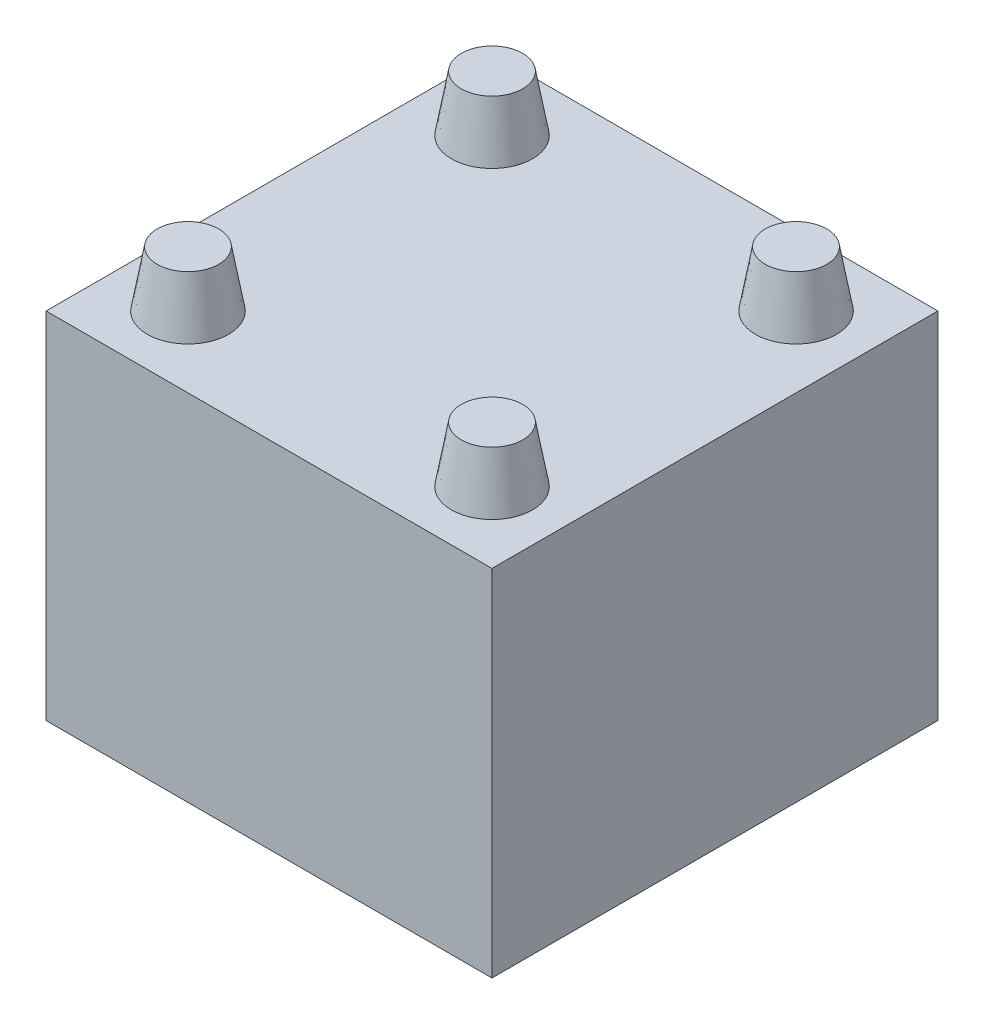
from build123d import *

# Parameters (mm, degrees)
SKETCH1_W           = 22
SKETCH1_H           = 22
BOSS_EXTRUDE1_DEPTH = 3
SKETCH2_R           = 2
BOSS_EXTRUDE2_DEPTH = 14.5
SKETCH3_R           = 2
BOSS_EXTRUDE3_DEPTH = 2.75
BOSS_EXTRUDE3_TAPER = 10
BOSS_EXTRUDE4_DEPTH = 14.5
BOSS_EXTRUDE5_DEPTH = 14.5
SKETCH6_W           = 22
SKETCH6_H           = 22
BOSS_EXTRUDE6_DEPTH = 14.5


with BuildPart() as part:
    # Sketch1 → Boss-Extrude1 (new body)
    with BuildSketch(Plane(origin=(0, 0, 0), x_dir=(1, 0, 0), z_dir=(0, 1, 0))):
        Rectangle(SKETCH1_W, SKETCH1_H)
    extrude(amount=BOSS_EXTRUDE1_DEPTH)

    # Sketch2 → Boss-Extrude2 (add)
    with BuildSketch(Plane(origin=(0, 3, 0), x_dir=(1, 0, 0), z_dir=(0, 1, 0))):
        with Locations((-7.5, 7.5)):
            Circle(SKETCH2_R)
        with Locations((7.5, 7.5)):
            Circle(SKETCH2_R)
        with Locations((7.5, -7.5)):
            Circle(SKETCH2_R)
        with Locations((-7.5, -7.5)):
            Circle(SKETCH2_R)
    extrude(amount=BOSS_EXTRUDE2_DEPTH)

    # Sketch3 → Boss-Extrude3 (add)
    with BuildSketch(Plane(origin=(0, 17.5, 0), x_dir=(1, 0, 0), z_dir=(0, 1, 0))):
        with Locations((7.5, -7.5)):
            Circle(SKETCH3_R)
        with Locations((7.5, 7.5)):
            Circle(SKETCH3_R)
        with Locations((-7.5, 7.5)):
            Circle(SKETCH3_R)
        with Locations((-7.5, -7.5)):
            Circle(SKETCH3_R)
    extrude(amount=BOSS_EXTRUDE3_DEPTH, taper=BOSS_EXTRUDE3_TAPER)

    # Sketch4 → Boss-Extrude4 (add)
    with BuildSketch(Plane(origin=(0, 3, 0), x_dir=(1, 0, 0), z_dir=(0, 1, 0))):
        Polygon((-7.217157288, -7.782842712), (7.782842712, 7.217157288), (7.217157288, 7.782842712), (-7.782842712, -7.217157288), align=None)
    extrude(amount=BOSS_EXTRUDE4_DEPTH)

    # Sketch5 → Boss-Extrude5 (add)
    with BuildSketch(Plane(origin=(0, 3, 0), x_dir=(1, 0, 0), z_dir=(0, 1, 0))):
        Polygon((-7.217157288, 7.782842712), (7.782842712, -7.217157288), (7.217157288, -7.782842712), (-7.782842712, 7.217157288), align=None)
    extrude(amount=BOSS_EXTRUDE5_DEPTH)

    # Sketch6 → Boss-Extrude6 (add)
    with BuildSketch(Plane(origin=(0, 3, 0), x_dir=(1, 0, 0), z_dir=(0, 1, 0))):
        Rectangle(SKETCH6_W, SKETCH6_H)
    extrude(amount=BOSS_EXTRUDE6_DEPTH)


solid = part.part
